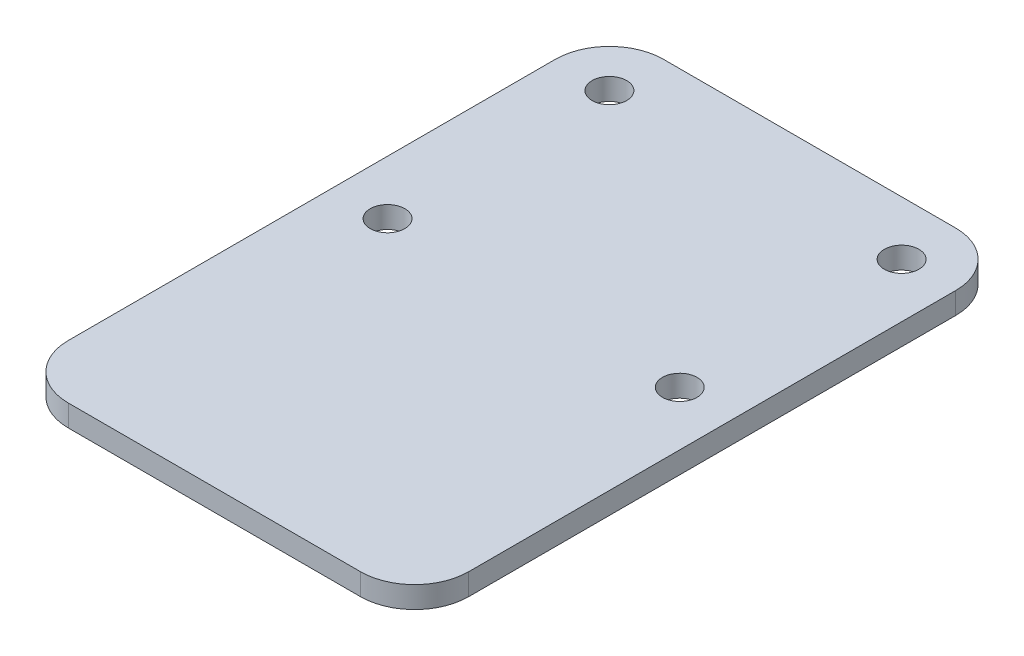
from build123d import *

# Parameters (mm, degrees)
CROQUIS1_W              = 37
CROQUIS1_H              = 55
CROQUIS1_R              = 1.6
SALIENTE_EXTRUIR1_DEPTH = 2
REDONDEO1_R             = 5


with BuildPart() as part:
    # Croquis1 → Saliente-Extruir1 (new body)
    with BuildSketch(Plane(origin=(0, 0, 0), x_dir=(1, 0, 0), z_dir=(0, 1, 0))):
        Rectangle(CROQUIS1_W, CROQUIS1_H)
        with Locations((-13.5, 22.5)):
            Circle(CROQUIS1_R, mode=Mode.SUBTRACT)
        with Locations((-13.5, 2)):
            Circle(CROQUIS1_R, mode=Mode.SUBTRACT)
        with Locations((13.5, 2)):
            Circle(CROQUIS1_R, mode=Mode.SUBTRACT)
        with Locations((13.5, 22.5)):
            Circle(CROQUIS1_R, mode=Mode.SUBTRACT)
    extrude(amount=SALIENTE_EXTRUIR1_DEPTH)

    # Redondeo1
    redondeo1_edges = [part.edges().sort_by_distance(p)[0] for p in [
        (18.5, 1, 27.5),
        (-18.5, 1, 27.5),
        (-18.5, 1, -27.5),
        (18.5, 1, -27.5),
    ]]
    fillet(redondeo1_edges, radius=REDONDEO1_R)


solid = part.part
